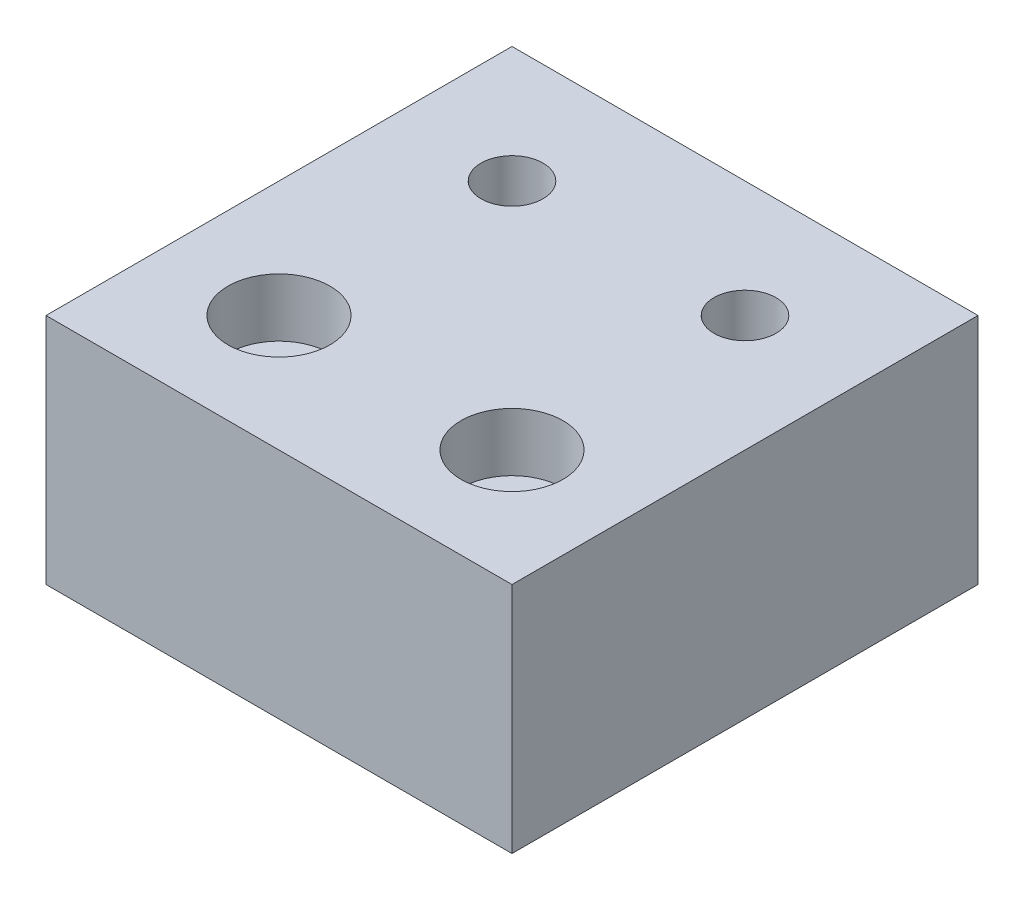
from build123d import *

# Parameters (mm, degrees)
SKETCH1_W                                        = 101.6
SKETCH1_H                                        = 50.8
BOSS_EXTRUDE1_DEPTH                              = 25.4
CBORE_FOR_1_4_SOCKET_HEAD_CAP_SCREW1_D           = 6.7564
CBORE_FOR_1_4_SOCKET_HEAD_CAP_SCREW1_CBORE_D     = 11.1125
CBORE_FOR_1_4_SOCKET_HEAD_CAP_SCREW1_CBORE_DEPTH = 6.35
LPATTERN1_COUNT                                  = 4
LPATTERN1_PITCH                                  = 25.4
F_1_4_CLEARANCE_HOLE1_D                          = 6.7564
LPATTERN2_COUNT                                  = 4
LPATTERN2_PITCH                                  = 25.4
SKETCH7_W                                        = 50.8
SKETCH7_H                                        = 25.4
CUT_EXTRUDE1_DEPTH                               = 50.8


with BuildPart() as part:
    # Sketch1 → Boss-Extrude1 (new body)
    with BuildSketch(Plane(origin=(0, 0, 0), x_dir=(1, 0, 0), z_dir=(0, 1, 0))):
        with Locations((50.8, 25.4)):
            Rectangle(SKETCH1_W, SKETCH1_H)
    extrude(amount=BOSS_EXTRUDE1_DEPTH)

    # CBORE for 1/4 Socket Head Cap Screw1 (through all)
    with Locations(Plane(origin=(0, 25.4, 0), x_dir=(-1, 0, 0), z_dir=(0, 1, 0))):
        with Locations((-12.7, -12.7)):
            cbore_for_1_4_socket_head_cap_screw1 = CounterBoreHole(CBORE_FOR_1_4_SOCKET_HEAD_CAP_SCREW1_D / 2, CBORE_FOR_1_4_SOCKET_HEAD_CAP_SCREW1_CBORE_D / 2, CBORE_FOR_1_4_SOCKET_HEAD_CAP_SCREW1_CBORE_DEPTH)

    # LPattern1: CBORE for 1/4 Socket Head Cap Screw1 ×4
    with Locations(*[(i * LPATTERN1_PITCH, 0, 0) for i in range(1, LPATTERN1_COUNT)]):
        add(cbore_for_1_4_socket_head_cap_screw1, mode=Mode.SUBTRACT)

    # 1/4 Clearance Hole1 (through all)
    with Locations(Plane(origin=(0, 25.4, 0), x_dir=(-1, 0, 0), z_dir=(0, 1, 0))):
        with Locations((-12.7, -38.1)):
            f_1_4_clearance_hole1 = Hole(F_1_4_CLEARANCE_HOLE1_D / 2)

    # LPattern2: 1/4 Clearance Hole1 ×4
    with Locations(*[(i * LPATTERN2_PITCH, 0, 0) for i in range(1, LPATTERN2_COUNT)]):
        add(f_1_4_clearance_hole1, mode=Mode.SUBTRACT)

    # Sketch7 → Cut-Extrude1 (cut)
    with BuildSketch(Plane(origin=(101.6, 0, 0), x_dir=(0, 0, -1), z_dir=(1, 0, 0))):
        with Locations((25.4, 12.7)):
            Rectangle(SKETCH7_W, SKETCH7_H)
    extrude(amount=-CUT_EXTRUDE1_DEPTH, mode=Mode.SUBTRACT)


solid = part.part
